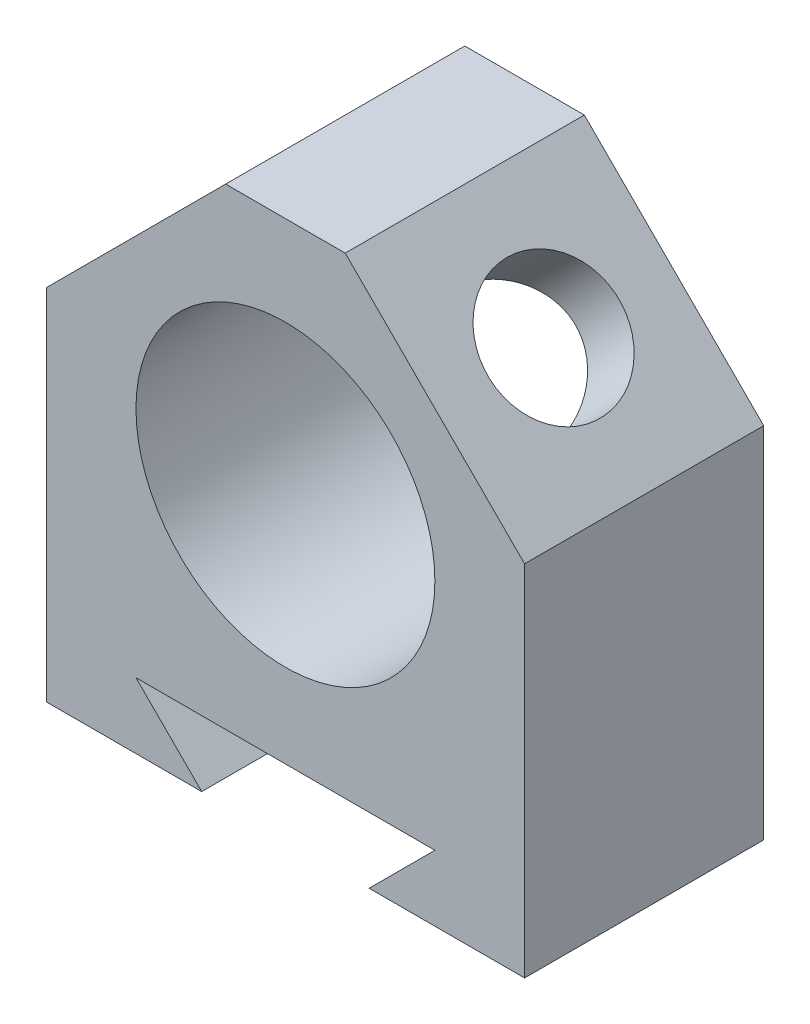
from build123d import *

# Parameters (mm, degrees)
SKETCH1_R           = 25
BOSS_EXTRUDE1_DEPTH = 40
CUT_EXTRUDE1_REACH  = 100.995
SKETCH2_R           = 11
CUT_EXTRUDE3_REACH  = 100.995


with BuildPart() as part:
    # Sketch1 → Boss-Extrude1 (new body)
    with BuildSketch(Plane.XY):
        Polygon((25, 0), (-25, 0), (-14, -11), (-40, -11), (-40, 49), (-10, 79), (0, 79), (10, 79), (40, 49), (40, -11), (14, -11), align=None)
        with Locations((0, 39)):
            Circle(SKETCH1_R, mode=Mode.SUBTRACT)
    extrude(amount=-BOSS_EXTRUDE1_DEPTH)

    # Sketch2 → Cut-Extrude1 (cut, up to next)
    with BuildSketch(Plane(origin=(44.5, 44.5, 0), x_dir=(0, 0, -1), z_dir=(0.707106781, 0.707106781, 0)), mode=Mode.PRIVATE) as cut_extrude1_sk1:
        with Locations((20, 27.790367902)):
            Circle(SKETCH2_R)
    cut_extrude1_tool1 = extrude(cut_extrude1_sk1.sketch, amount=-CUT_EXTRUDE1_REACH, mode=Mode.PRIVATE) & part.part
    add(cut_extrude1_tool1.solids().sort_by_distance((24.849242, 64.150758, -20))[0], mode=Mode.SUBTRACT)

    # Sketch3 → Cut-Extrude3 (cut, up to next)
    with BuildSketch(Plane(origin=(-44.5, 44.5, 0), x_dir=(0, 0, 1), z_dir=(-0.707106781, 0.707106781, 0)), mode=Mode.PRIVATE) as cut_extrude3_sk1:
        Polygon((-8.452994616, 27.790367902), (-14.226497308, 37.790367902), (-25.773502692, 37.790367902), (-31.547005384, 27.790367902), (-25.773502692, 17.790367902), (-14.226497308, 17.790367902), align=None)
    cut_extrude3_tool1 = extrude(cut_extrude3_sk1.sketch, amount=-CUT_EXTRUDE3_REACH, mode=Mode.PRIVATE) & part.part
    add(cut_extrude3_tool1.solids().sort_by_distance((-24.849242, 64.150758, -20))[0], mode=Mode.SUBTRACT)


solid = part.part
